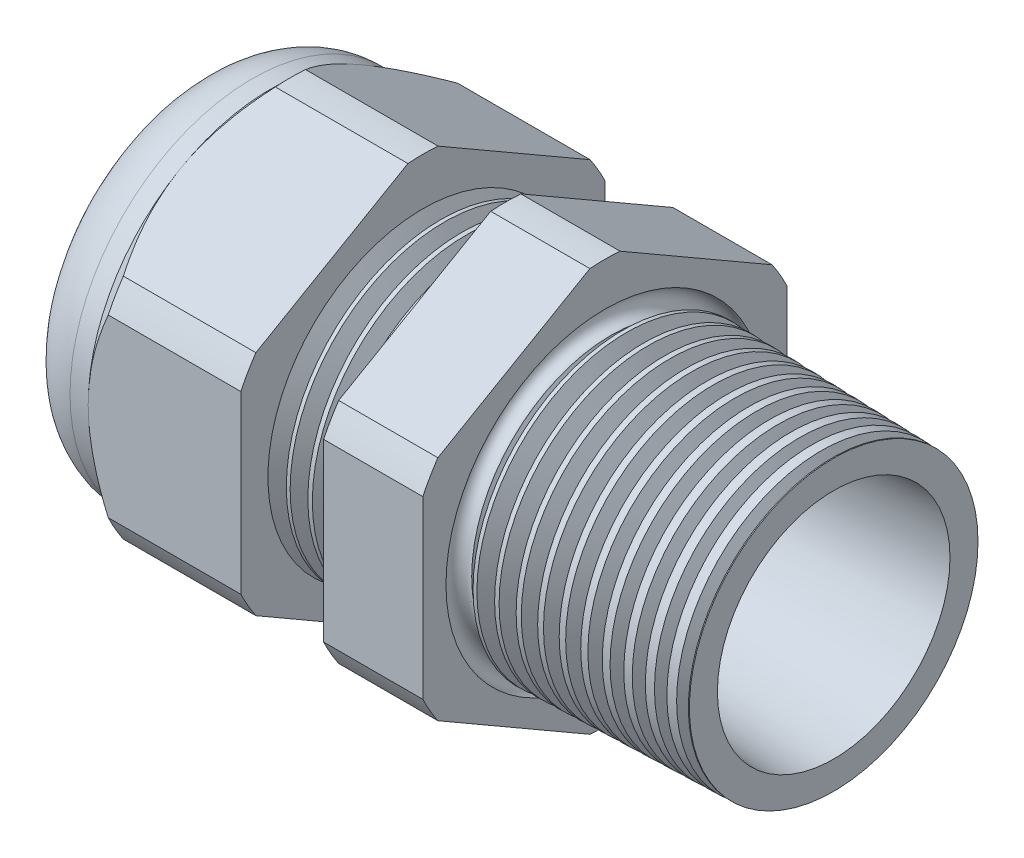
from build123d import *

# Parameters (mm, degrees)
LPATTERN6_COUNT    = 4
LPATTERN6_PITCH    = 1.397
LPATTERN7_COUNT    = 11
LPATTERN7_PITCH    = 1.397
SKETCH12_OUTSIDE_W = 65.648
SKETCH12_OUTSIDE_H = 65.648
CUT_EXTRUDE2_DEPTH = 37.91
FILLET4_R          = 3.81
SKETCH19_OUTSIDE_W = 40.884
SKETCH19_OUTSIDE_H = 43.51
SKETCH19_OUTSIDE_R = 11.938
CUT_EXTRUDE3_DEPTH = 1.999996
CUT_EXTRUDE3_DRAFT = -45
SKETCH28_R         = 0.6985


with BuildPart() as part:
    # Sketch10 → Revolve2 (revolve)
    with BuildSketch(Plane.XY, mode=Mode.PRIVATE) as revolve2_sk:
        Polygon((-29.798, 5.969), (-19.798, 5.969), (7.112, 7.62), (7.112, 9.455336851), (-7.874, 9.847759071), (-7.874, 23.876), (-14.374, 23.876), (-14.374, 10.017967561), (-19.798, 10.16), (-19.798, 23.876), (-29.798, 23.876), (-29.798, 11.938), (-34.798, 11.938), (-34.798, 7.62), (-29.798, 7.62), align=None)
    revolve(revolve2_sk.sketch.rotate(Axis((0, 0, 0), (-1, 0, 0)), 90), axis=Axis((0, 0, 0), (-1, 0, 0)))  # turned: the seam where the file's is

    # Sketch26 → Cut-Revolve1 (revolve, cut)
    with BuildSketch(Plane.XY, mode=Mode.PRIVATE) as cut_revolve1_sk:
        Polygon((-19.798, 10.16), (-18.625226271, 10.129289839), (-19.238208915, 9.128993077), align=None)
    cut_revolve1 = revolve(cut_revolve1_sk.sketch.rotate(Axis((0, 0, 0), (-1, 0, 0)), 90), axis=Axis((0, 0, 0), (-1, 0, 0)), mode=Mode.SUBTRACT)  # turned: the seam where the file's is

    # LPattern6: Cut-Revolve1 ×4
    with Locations(*[(i * LPATTERN6_PITCH, 0, 0) for i in range(1, LPATTERN6_COUNT)]):
        add(cut_revolve1, mode=Mode.SUBTRACT)

    # Sketch27 → Cut-Revolve2 (revolve, cut)
    with BuildSketch(Plane.XY, mode=Mode.PRIVATE) as cut_revolve2_sk:
        Polygon((-7.874, 9.847759071), (-6.701226271, 9.81704891), (-7.314208915, 8.816752149), align=None)
    cut_revolve2 = revolve(cut_revolve2_sk.sketch.rotate(Axis((0, 0, 0), (-1, 0, 0)), 90), axis=Axis((0, 0, 0), (-1, 0, 0)), mode=Mode.SUBTRACT)  # turned: the seam where the file's is

    # LPattern7: Cut-Revolve2 ×11
    with Locations(*[(i * LPATTERN7_PITCH, 0, 0) for i in range(1, LPATTERN7_COUNT)]):
        add(cut_revolve2, mode=Mode.SUBTRACT)

    # Sketch12 outside → Cut-Extrude2 (cut, through all)
    with BuildSketch(Plane.ZY.offset(29.798)):
        Rectangle(SKETCH12_OUTSIDE_W, SKETCH12_OUTSIDE_H)
        with BuildLine():
            Line((-0.98819228, 13.214281948), (-10.94980772, 7.462940592))
            ThreePointArc((-10.94980772, 7.462940592), (-11.47585851, 6.62559), (-11.938, 5.751341356))
            Line((-11.938, 5.751341356), (-11.938, -5.751341356))
            ThreePointArc((-11.938, -5.751341356), (-11.47585851, -6.62559), (-10.94980772, -7.462940592))
            Line((-10.94980772, -7.462940592), (-0.98819228, -13.214281948))
            ThreePointArc((-0.98819228, -13.214281948), (0, -13.25118), (0.98819228, -13.214281948))
            Line((0.98819228, -13.214281948), (10.94980772, -7.462940592))
            ThreePointArc((10.94980772, -7.462940592), (11.47585851, -6.62559), (11.938, -5.751341356))
            Line((11.938, -5.751341356), (11.938, 5.751341356))
            ThreePointArc((11.938, 5.751341356), (11.47585851, 6.62559), (10.94980772, 7.462940592))
            Line((10.94980772, 7.462940592), (0.98819228, 13.214281948))
            ThreePointArc((0.98819228, 13.214281948), (0, 13.25118), (-0.98819228, 13.214281948))
        make_face(mode=Mode.SUBTRACT)
    extrude(amount=-CUT_EXTRUDE2_DEPTH, mode=Mode.SUBTRACT)

    # Fillet4
    fillet4_edges = [part.edges().sort_by_distance(p)[0] for p in [
        (-34.798, 0, 11.938),
    ]]
    fillet(fillet4_edges, radius=FILLET4_R)


with BuildPart() as body_2:
    # Sketch23 → Revolve6 (revolve)
    with BuildSketch(Plane.XY, mode=Mode.PRIVATE) as revolve6_sk:
        with BuildLine():
            Line((-33.8074, 7.62), (-29.798, 7.62))
            Line((-29.798, 7.62), (-29.798, 5.969))
            Line((-29.798, 5.969), (-34.036, 5.969))
            Line((-34.036, 5.969), (-34.036, 7.3914))
            ThreePointArc((-34.036, 7.3914), (-33.96904461, 7.55304461), (-33.8074, 7.62))
        make_face()
    revolve(revolve6_sk.sketch.rotate(Axis((0, 0, 0), (-1, 0, 0)), 90), axis=Axis((0, 0, 0), (-1, 0, 0)))  # turned: the seam where the file's is


with BuildPart() as cut_extrude3_tool:
    # Sketch19 outside → Cut-Extrude3 (with draft: the straight prism first)
    with BuildSketch(Plane.ZY.offset(29.798)):
        Rectangle(SKETCH19_OUTSIDE_W, SKETCH19_OUTSIDE_H)
        Circle(SKETCH19_OUTSIDE_R, mode=Mode.SUBTRACT)
    extrude(amount=-CUT_EXTRUDE3_DEPTH)
    # Cut-Extrude3: the draft: its side faces are tilted about the plane it starts from
    cut_extrude3_sides = [cut_extrude3_tool.faces().sort_by_distance(p)[0] for p in [
        (-28.798002, -21.755, 0),
        (-28.798002, 0, 20.442),
        (-28.798002, 21.755, 0),
        (-28.798002, 0, -20.442),
        (-28.798002, 0, -11.938),
    ]]
    draft(cut_extrude3_sides, Plane.ZY.offset(29.798), CUT_EXTRUDE3_DRAFT)


with BuildPart() as part_1:
    add(part.part)

    # Cut-Extrude3: cut by cut_extrude3_tool
    add(cut_extrude3_tool.part, mode=Mode.SUBTRACT)

    # Sketch28 → Cut-Revolve3 (revolve, cut)
    with BuildSketch(Plane.XY, mode=Mode.PRIVATE) as cut_revolve3_sk:
        with Locations((-7.8486, -9.720759071)):
            Circle(SKETCH28_R)
    revolve(cut_revolve3_sk.sketch.rotate(Axis((7.112, 0, 0), (-1, 0, 0)), 90), axis=Axis((7.112, 0, 0), (-1, 0, 0)), mode=Mode.SUBTRACT)  # turned: the seam where the file's is


solid = Compound([body_2.part, part_1.part])
